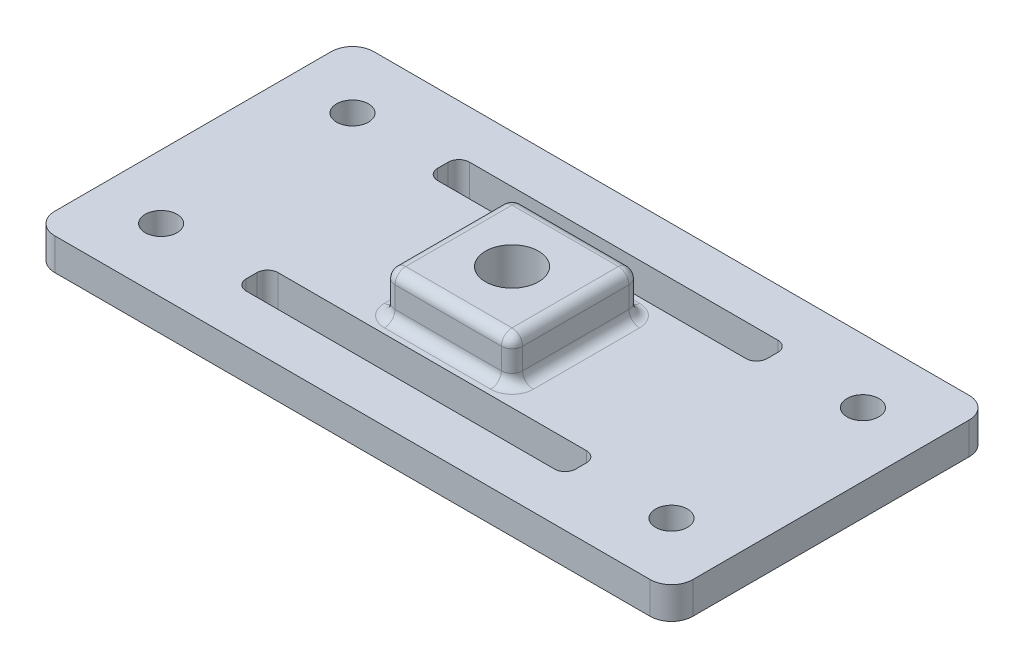
from build123d import *

# Parameters (mm, degrees)
SKETCH_1_W               = 60
SKETCH_1_H               = 30
EXTRUDE_1_DEPTH          = 3
SKETCH_2_R               = 1.5
CUT_EXTRUDE_1_DEPTH      = 3
SKETCH_5_W               = 12
SKETCH_5_H               = 12
EXTRUDE_2_DEPTH          = 4
MIRROR_2_COPY_1_SKETCH_R = 1.5
MIRROR_2_COPY_1_DEPTH    = 3
SKETCH_3_W               = 30.992816336
SKETCH_3_H               = 3
CUT_EXTRUDE_2_DEPTH      = 3
FILLET_1_R               = 1
FILLET_1_OF_MIRROR_3_R   = 1
FILLET_2_R               = 2
SKETCH_4_R               = 2.5
CUT_EXTRUDE_3_DEPTH      = 5
CUT_EXTRUDE_3_DEPTH_BACK = 4
FILLET_3_R               = 1


with BuildPart() as part:
    # 草图1 → 凸台-拉伸1 (new body)
    with BuildSketch(Plane(origin=(0, 0, 0), x_dir=(1, 0, 0), z_dir=(0, 1, 0))):
        Rectangle(SKETCH_1_W, SKETCH_1_H)
    extrude(amount=EXTRUDE_1_DEPTH)

    # 草图2 → 切除-拉伸1 (cut)
    with BuildSketch(Plane(origin=(0, 3, 0), x_dir=(1, 0, 0), z_dir=(0, 1, 0))):
        with Locations((-24, -9)):
            Circle(SKETCH_2_R)
    cut_extrude_1 = extrude(amount=-CUT_EXTRUDE_1_DEPTH, mode=Mode.SUBTRACT)

    # 草图5 → 凸台-拉伸2 (add)
    with BuildSketch(Plane(origin=(0, 3, 0), x_dir=(1, 0, 0), z_dir=(0, 1, 0))):
        Rectangle(SKETCH_5_W, SKETCH_5_H)
    extrude(amount=EXTRUDE_2_DEPTH)

    # 镜向1: 切除-拉伸1 across plane
    add(cut_extrude_1.mirror(Plane.XY), mode=Mode.SUBTRACT)

    # 镜向2: 切除-拉伸1 across plane
    add(cut_extrude_1.mirror(Plane(origin=(0, 0, 0), x_dir=(0, 0, 1), z_dir=(1, 0, 0))), mode=Mode.SUBTRACT)

    # 镜向2 copy 1 sketch → 镜向2 copy 1 (cut)
    with BuildSketch(Plane(origin=(0, 3, 0), x_dir=(-1, 0, 0), z_dir=(0, 1, 0))):
        with Locations((-24, -9)):
            Circle(MIRROR_2_COPY_1_SKETCH_R)
    extrude(amount=-MIRROR_2_COPY_1_DEPTH, mode=Mode.SUBTRACT)

    # 草图3 → 切除-拉伸2 (cut)
    with BuildSketch(Plane(origin=(0, 3, 0), x_dir=(1, 0, 0), z_dir=(0, 1, 0))):
        with Locations((0, -9)):
            Rectangle(SKETCH_3_W, SKETCH_3_H)
    cut_extrude_2 = extrude(amount=-CUT_EXTRUDE_2_DEPTH, mode=Mode.SUBTRACT)

    # 圆角1
    fillet_1_edges = [part.edges().sort_by_distance(p)[0] for p in [
        (-15.496408168, 1.5, 10.5),
        (-15.496408168, 1.5, 7.5),
        (15.496408168, 1.5, 7.5),
        (15.496408168, 1.5, 10.5),
    ]]
    fillet(fillet_1_edges, radius=FILLET_1_R)

    # 镜向3: 切除-拉伸2 across plane
    add(cut_extrude_2.mirror(Plane.XY), mode=Mode.SUBTRACT)

    # 圆角1 of 镜向3
    fillet_1_of_mirror_3_edges = [part.edges().sort_by_distance(p)[0] for p in [
        (-15.496408168, 1.5, -10.5),
        (-15.496408168, 1.5, -7.5),
        (15.496408168, 1.5, -7.5),
        (15.496408168, 1.5, -10.5),
    ]]
    fillet(fillet_1_of_mirror_3_edges, radius=FILLET_1_OF_MIRROR_3_R)

    # 圆角2
    fillet_2_edges = [part.edges().sort_by_distance(p)[0] for p in [
        (-30, 1.5, -15),
        (30, 1.5, -15),
        (30, 1.5, 15),
        (-30, 1.5, 15),
    ]]
    fillet(fillet_2_edges, radius=FILLET_2_R)

    # 草图4 → 切除-拉伸3 (cut, two sides)
    with BuildSketch(Plane(origin=(0, 3, 0), x_dir=(1, 0, 0), z_dir=(0, 1, 0))) as cut_extrude_3_sk:
        Circle(SKETCH_4_R)
    extrude(amount=CUT_EXTRUDE_3_DEPTH, mode=Mode.SUBTRACT)
    extrude(cut_extrude_3_sk.sketch, amount=-CUT_EXTRUDE_3_DEPTH_BACK, mode=Mode.SUBTRACT)

    # 圆角3
    fillet_3_edges = [part.edges().sort_by_distance(p)[0] for p in [
        (-6, 3, 0),
        (-6, 5, -6),
        (0, 3, 6),
        (-6, 5, 6),
        (6, 3, 0),
        (6, 5, 6),
        (0, 3, -6),
        (6, 5, -6),
        (-6, 7, 0),
        (0, 7, 6),
        (6, 7, 0),
        (0, 7, -6),
    ]]
    fillet(fillet_3_edges, radius=FILLET_3_R)


solid = part.part
